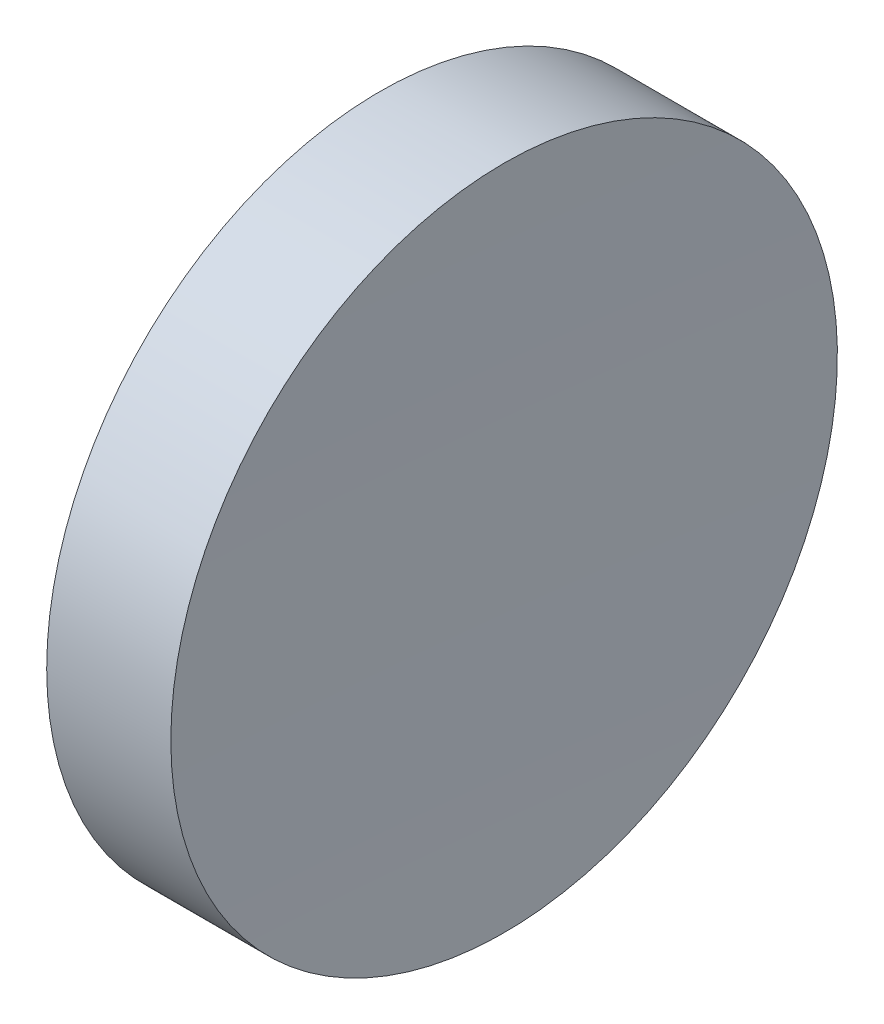
from build123d import *


with BuildPart() as part:
    # 草图1 → 旋转1 (revolve)
    with BuildSketch(Plane.XY):
        with BuildLine():
            Line((230.18531107, 138.756042247), (230.18531107, 163.756042247))
            Line((230.18531107, 163.756042247), (239.497858858, 163.756042247))
            ThreePointArc((239.497858858, 163.756042247), (239.263450279, 151.257019076), (239.185310015, 138.756042247))
            Line((239.185310015, 138.756042247), (230.18531107, 138.756042247))
        make_face()
    revolve(axis=Axis((217.970286004, 138.756042247, 0), (1, 0, 0)))


solid = part.part
